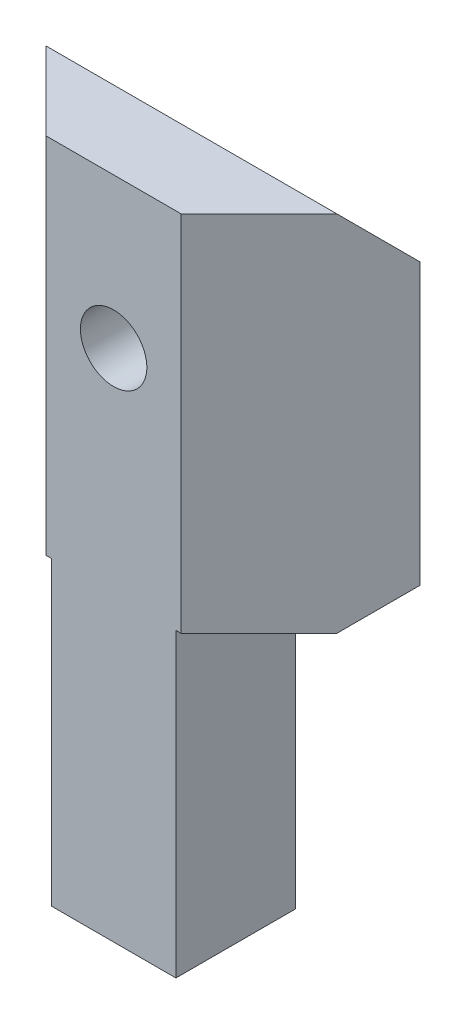
from build123d import *

# Parameters (mm, degrees)
BOSS_EXTRUDE1_DEPTH = 32
CHAMFER1_SIZE       = 2
CUT_EXTRUDE1_DEPTH  = 14.5
CHAMFER2_SIZE       = 2
SKETCH3_R           = 1.625
CUT_EXTRUDE2_DEPTH  = 4
SKETCH4_R           = 1.6
CUT_EXTRUDE3_DEPTH  = 7
SKETCH5_R           = 2.875
CUT_EXTRUDE4_DEPTH  = 2.5
SKETCH6_W           = 9.951006948
SKETCH6_H           = 32
CUT_EXTRUDE5_DEPTH  = 0.25


with BuildPart() as part:
    # Sketch1 → Boss-Extrude1 (new body)
    with BuildSketch(Plane(origin=(0, 0, 0), x_dir=(1, 0, 0), z_dir=(0, 1, 0))):
        Polygon((-16.800646523, 6.80487106), (1.199353477, 6.80487106), (-4.800646523, 0.80487106), (-10.800646523, 0.80487106), align=None)
    extrude(amount=BOSS_EXTRUDE1_DEPTH)

    # Chamfer1
    chamfer1_edges = [part.edges().sort_by_distance(p)[0] for p in [
        (-7.800646523, 32, -6.80487106),
    ]]
    chamfer(chamfer1_edges, length=CHAMFER1_SIZE)

    # Sketch2 → Cut-Extrude1 (cut)
    with BuildSketch(Plane.XZ):
        Polygon((-4.800646523, -0.80487106), (-4.800646523, -6.80487106), (1.199353477, -6.80487106), align=None)
        Polygon((-10.800646523, -0.80487106), (-10.800646523, -6.80487106), (-16.800646523, -6.80487106), align=None)
    extrude(amount=-CUT_EXTRUDE1_DEPTH, mode=Mode.SUBTRACT)

    # Chamfer2
    chamfer2_edges = [part.edges().sort_by_distance(p)[0] for p in [
        (-1.800646523, 14.5, -6.80487106),
        (-13.800646523, 14.5, -6.80487106),
    ]]
    chamfer(chamfer2_edges, length=CHAMFER2_SIZE)

    # Sketch3 → Cut-Extrude2 (cut)
    with BuildSketch(Plane.XZ):
        with Locations((-7.800646523, -3.80487106)):
            Circle(SKETCH3_R)
    extrude(amount=-CUT_EXTRUDE2_DEPTH, mode=Mode.SUBTRACT)

    # Sketch4 → Cut-Extrude3 (cut, through all)
    with BuildSketch(Plane(origin=(0, 0, -6.80487106), x_dir=(-1, 0, 0), z_dir=(0, 0, -1))):
        with Locations((7.800646523, 24.7693)):
            Circle(SKETCH4_R)
    extrude(amount=-CUT_EXTRUDE3_DEPTH, mode=Mode.SUBTRACT)

    # Sketch5 → Cut-Extrude4 (cut)
    with BuildSketch(Plane(origin=(0, 0, -6.80487106), x_dir=(-1, 0, 0), z_dir=(0, 0, -1))):
        with Locations((7.800646523, 24.7693)):
            Circle(SKETCH5_R)
    extrude(amount=-CUT_EXTRUDE4_DEPTH, mode=Mode.SUBTRACT)

    # Sketch6 → Cut-Extrude5 (cut)
    with BuildSketch(Plane.XY.offset(-0.80487106)):
        with Locations((-7.355555637, 16)):
            Rectangle(SKETCH6_W, SKETCH6_H)
    extrude(amount=-CUT_EXTRUDE5_DEPTH, mode=Mode.SUBTRACT)


solid = part.part
